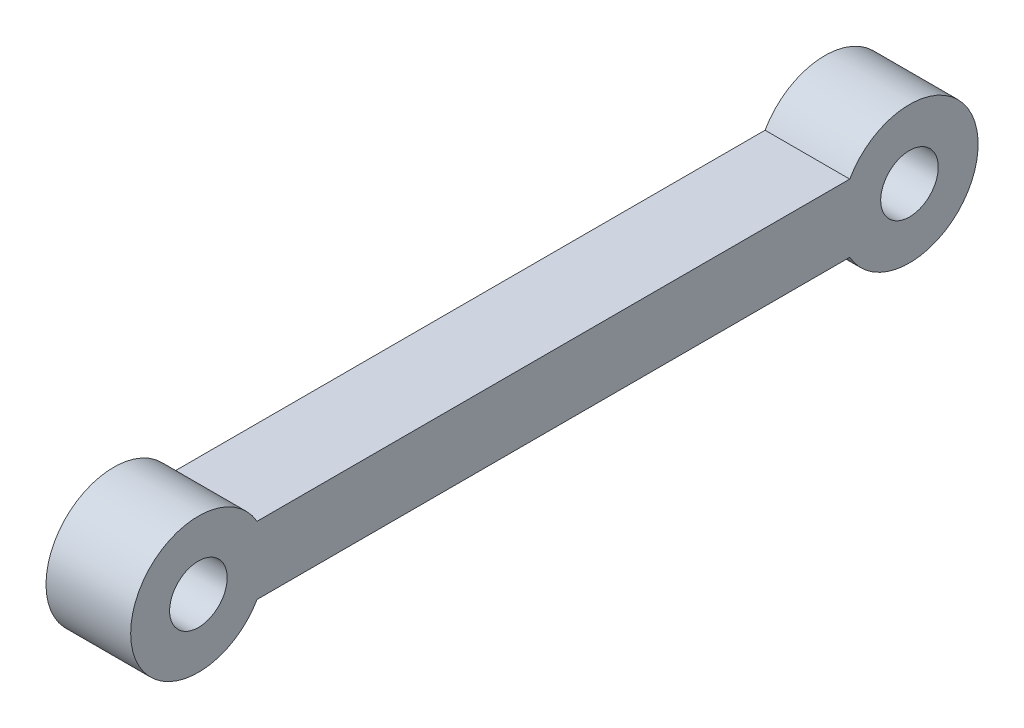
from build123d import *

# Parameters (mm, degrees)
SKETCH_1_R      = 1.7
EXTRUDE_1_DEPTH = 5


with BuildPart() as part:
    # Эскиз1 → Бобышка-Вытянуть1 (new body)
    with BuildSketch(Plane.ZY.offset(-0.758160047)):
        with BuildLine():
            Line((-40.531827395, 59.814835282), (-5.531827395, 59.814835282))
            ThreePointArc((-5.531827395, 59.814835282), (1.93227422, 57.814835282), (-5.531827395, 55.814835282))
            Line((-5.531827395, 55.814835282), (-40.531827395, 55.814835282))
            ThreePointArc((-40.531827395, 55.814835282), (-48.114294617, 57.814835282), (-40.531827395, 59.814835282))
        make_face()
        with Locations((-2.06772578, 57.814835282)):
            Circle(SKETCH_1_R, mode=Mode.SUBTRACT)
        with Locations((-44.059294617, 57.814835282)):
            Circle(SKETCH_1_R, mode=Mode.SUBTRACT)
    extrude(amount=EXTRUDE_1_DEPTH)


solid = part.part
